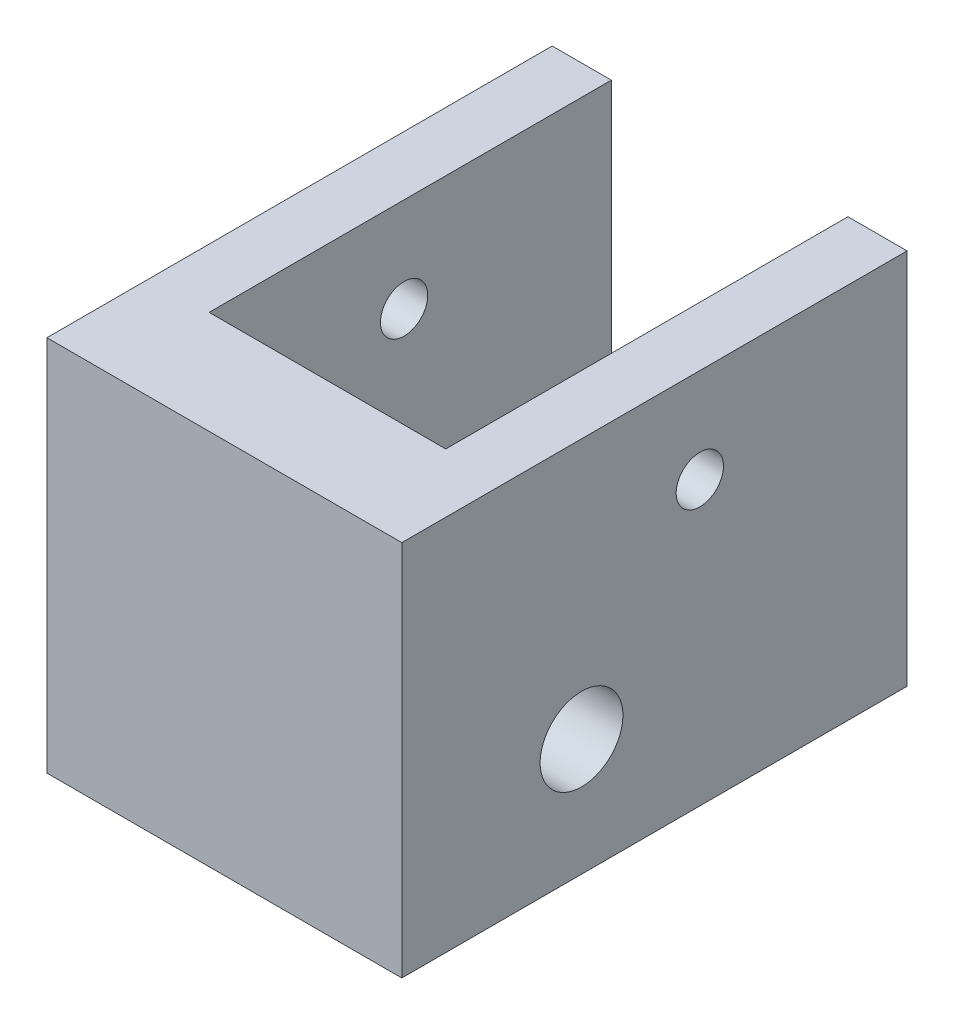
from build123d import *

# Parameters (mm, degrees)
SKETCH1_W           = 21.356696791
SKETCH1_H           = 15.93739856
SKETCH1_R           = 1.75
SKETCH1_R_2         = 1
BOSS_EXTRUDE1_DEPTH = 15
CUT_EXTRUDE1_REACH  = 17.937
SKETCH2_W           = 10
SKETCH2_H           = 17


with BuildPart() as part:
    # Sketch1 → Boss-Extrude1 (new body)
    with BuildSketch(Plane(origin=(0, 0, 0), x_dir=(0, 0, -1), z_dir=(1, 0, 0))):
        with Locations((3.081269675, 3.021892184)):
            Rectangle(SKETCH1_W, SKETCH1_H)
        Circle(SKETCH1_R, mode=Mode.SUBTRACT)
        with Locations((5, 7)):
            Circle(SKETCH1_R_2, mode=Mode.SUBTRACT)
    extrude(amount=BOSS_EXTRUDE1_DEPTH)

    # Sketch2 → Cut-Extrude1 (cut, up to next)
    with BuildSketch(Plane(origin=(0, 10.990591464, 0), x_dir=(1, 0, 0), z_dir=(0, 1, 0)), mode=Mode.PRIVATE) as cut_extrude1_sk1:
        with Locations((7.5, 5.259618071)):
            Rectangle(SKETCH2_W, SKETCH2_H)
    cut_extrude1_tool1 = extrude(cut_extrude1_sk1.sketch, amount=-CUT_EXTRUDE1_REACH, mode=Mode.PRIVATE) & part.part
    add(cut_extrude1_tool1.solids().sort_by_distance((7.5, 10.990591, -5.259618))[0], mode=Mode.SUBTRACT)


solid = part.part
